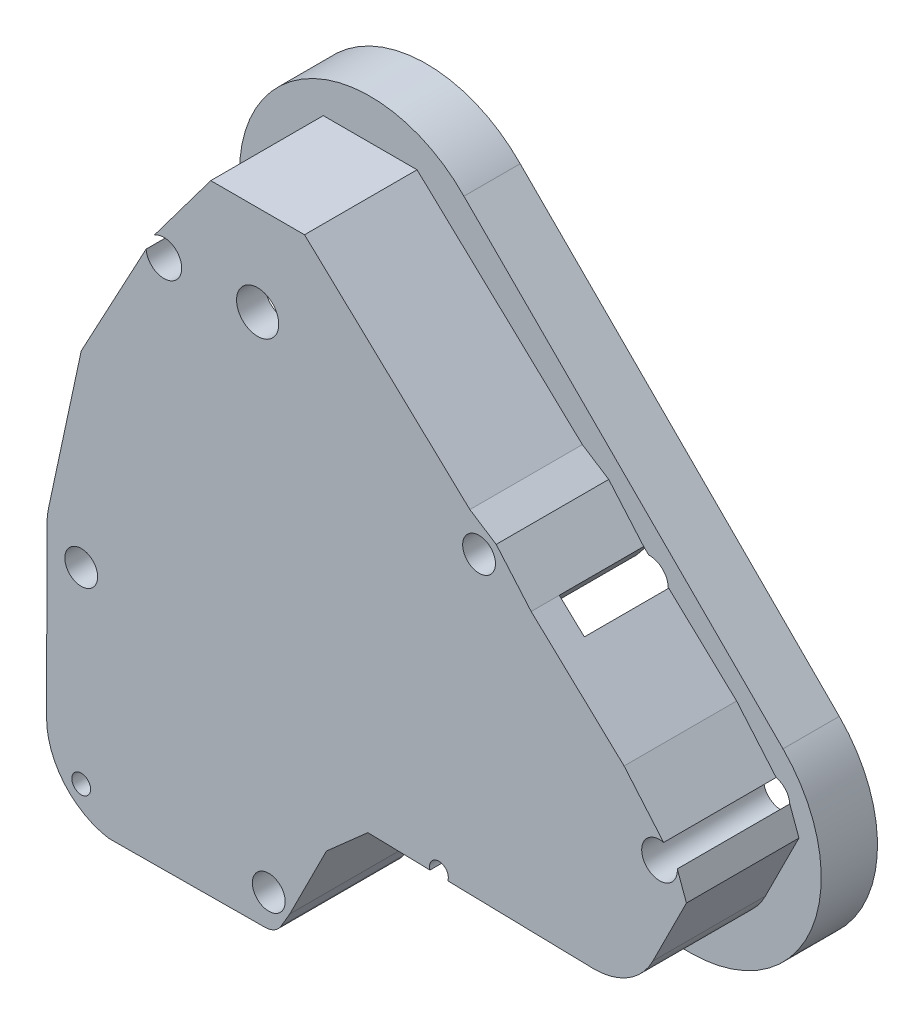
from build123d import *

# Parameters (mm, degrees)
SKETCH1_R                = 4.445
SKETCH1_R_2              = 2.54
BOSS_EXTRUDE1_DEPTH      = 27.94
SKETCH1_4_R              = 4.445
SKETCH1_4_R_2            = 2.667
BOSS_EXTRUDE2_DEPTH      = 5.08
BOSS_EXTRUDE3_DEPTH      = 2.54
BOSS_EXTRUDE4_DEPTH      = 2.54
BOSS_EXTRUDE4_DEPTH_BACK = 12.7
BOSS_EXTRUDE5_DEPTH      = 2.54
CUT_EXTRUDE2_DEPTH       = 28.94
BOSS_EXTRUDE7_DEPTH      = 2.54
SKETCH1_7_R              = 5.715
CUT_EXTRUDE1_DEPTH       = 28.94
BOSS_EXTRUDE6_DEPTH      = 2.54
SKETCH4_R                = 2.54
SKETCH4_R_2              = 4.445
SKETCH4_R_3              = 5.715
BOSS_EXTRUDE8_DEPTH      = 5.08
BOSS_EXTRUDE9_DEPTH      = 5.08


with BuildPart() as part:
    # Sketch1 → Boss-Extrude1 (new body)
    with BuildSketch(Plane.XY):
        with BuildLine():
            Line((6.529742955, -53.858421196), (8.86743597, -49.87006403))
            Line((8.86743597, -49.87006403), (18.794900521, -30.155662993))
            Line((18.794900521, -30.155662993), (30.015464801, -20.224261861))
            Line((30.015464801, -20.224261861), (90.906521033, -21.585518505))
            ThreePointArc((90.906521033, -21.585518505), (100.475537269, -19.041819588), (107.200283399, -11.7744772))
            Line((107.200283399, -11.7744772), (116.311189347, 6.409978492))
            Line((116.311189347, 6.409978492), (113.829291982, 13.184806868))
            ThreePointArc((113.829291982, 13.184806868), (105.340047507, 9.70868308), (110.132255745, 17.530795873))
            Line((110.132255745, 17.530795873), (99.420817942, 30.122447115))
            Line((99.420817942, 30.122447115), (81.037096807, 47.39593724))
            Line((81.037096807, 47.39593724), (81.2028603, 42.898970903))
            Line((81.2028603, 42.898970903), (102.978646989, 17.30080971))
            Line((102.978646989, 17.30080971), (101.915981854, 11.639329767))
            Line((101.915981854, 11.639329767), (108.017908886, 5.157985196))
            Line((108.017908886, 5.157985196), (96.90201237, -15.075571619))
            Line((96.90201237, -15.075571619), (69.399721914, -14.460741167))
            ThreePointArc((69.399721914, -14.460741167), (64.864546386, -17.364816007), (60.463681575, -14.260970544))
            Line((60.463681575, -14.260970544), (49.393136216, -14.01348176))
            Line((49.393136216, -14.01348176), (25.4, -16.5608))
            Line((25.4, -16.5608), (16.5608, -25.4))
            Line((16.5608, -25.4), (3.175, -41.558795918))
            Line((3.175, -41.558795918), (-23.8101989, -24.409795746))
            Line((-23.8101989, -24.409795746), (-41.068354942, 3.175))
            Line((-41.068354942, 3.175), (-41.068354942, 55.377447672))
            Line((-41.068354942, 55.377447672), (-31.251976081, 73.622391025))
            Line((-31.251976081, 73.622391025), (-15.891878201, 82.061036959))
            Line((-15.891878201, 82.061036959), (-10.836023731, 105.600550299))
            Line((-10.836023731, 105.600550299), (2.486172742, 105.600550299))
            Line((2.486172742, 105.600550299), (20.916306787, 88.283450236))
            ThreePointArc((20.916306787, 88.283450236), (28.864622049, 90.486498065), (27.160323343, 82.416522777))
            Line((27.160323343, 82.416522777), (61.243243186, 50.391941083))
            Line((61.243243186, 50.391941083), (64.972407605, 52.198379473))
            Line((64.972407605, 52.198379473), (69.788594683, 48.28291809))
            Line((69.788594683, 48.28291809), (74.25115565, 53.77206135))
            Line((74.25115565, 53.77206135), (64.777919112, 64.777919112))
            Line((64.777919112, 64.777919112), (57.647971379, 69.372544921))
            Line((57.647971379, 69.372544921), (12.859978492, 111.455698118))
            Line((12.859978492, 111.455698118), (-12.540021508, 111.455698118))
            Line((-12.540021508, 111.455698118), (-27.811486315, 91.053304566))
            ThreePointArc((-27.811486315, 91.053304566), (-20.936169847, 84.786075459), (-30.05423809, 86.632414738))
            Line((-30.05423809, 86.632414738), (-47.625, 53.975))
            Line((-47.625, 53.975), (-56.507300171, 12.537235488))
            ThreePointArc((-56.507300171, 12.537235488), (-56.803208534, 10.684397755), (-56.902212174, 8.810693482))
            Line((-56.902212174, 8.810693482), (-56.902212174, -38.910026796))
            ThreePointArc((-56.902212174, -38.910026796), (-51.522576099, -50.610202451), (-40.158446167, -56.667524098))
            Line((-40.158446167, -56.667524098), (2.147088913, -56.369619228))
            ThreePointArc((2.147088913, -56.369619228), (4.672646871, -55.697334849), (6.529742955, -53.858421196))
        make_face()
        with Locations((-47.625, 3.175)):
            Circle(SKETCH1_R, mode=Mode.SUBTRACT)
        with Locations((60.138073453, 60.138073453)):
            Circle(SKETCH1_R, mode=Mode.SUBTRACT)
        with Locations((3.175, -47.625)):
            Circle(SKETCH1_R, mode=Mode.SUBTRACT)
        with Locations((-47.625, -47.625)):
            Circle(SKETCH1_R_2, mode=Mode.SUBTRACT)
    extrude(amount=BOSS_EXTRUDE1_DEPTH)

    # Sketch1_4 → Boss-Extrude2 (add)
    with BuildSketch(Plane.XY):
        with Locations((-47.625, 3.175)):
            Circle(SKETCH1_4_R)
        with Locations((-47.625, 3.175)):
            Circle(SKETCH1_4_R_2, mode=Mode.SUBTRACT)
        with Locations((3.175, -47.625)):
            Circle(SKETCH1_4_R)
        with Locations((3.175, -47.625)):
            Circle(SKETCH1_4_R_2, mode=Mode.SUBTRACT)
        with Locations((60.138073453, 60.138073453)):
            Circle(SKETCH1_4_R)
        with Locations((60.138073453, 60.138073453)):
            Circle(SKETCH1_4_R_2, mode=Mode.SUBTRACT)
    extrude(amount=BOSS_EXTRUDE2_DEPTH)

    # Sketch1_5 → Boss-Extrude3 (add)
    with BuildSketch(Plane.XY):
        with BuildLine():
            ThreePointArc((21.234247588, 108.745854575), (-11.894017134, 114.773008011), (-30.140021508, 86.472975741))
            Line((-30.140021508, 86.472975741), (-30.05423809, 86.632414738))
            ThreePointArc((-30.05423809, 86.632414738), (-29.543873169, 89.152830265), (-27.811486315, 91.053304566))
            Line((-27.811486315, 91.053304566), (-12.540021508, 111.455698118))
            Line((-12.540021508, 111.455698118), (12.859978492, 111.455698118))
            Line((12.859978492, 111.455698118), (57.647971379, 69.372544921))
            Line((57.647971379, 69.372544921), (64.777919112, 64.777919112))
            Line((64.777919112, 64.777919112), (74.25115565, 53.77206135))
            Line((74.25115565, 53.77206135), (75.634193234, 52.472548271))
            ThreePointArc((75.634193234, 52.472548271), (76.84224881, 52.371963391), (77.992077705, 51.988024458))
            Line((77.992077705, 51.988024458), (59.152987425, 70.827114739))
            Line((59.152987425, 70.827114739), (21.936380205, 108.043721958))
            Line((21.936380205, 108.043721958), (21.234247588, 108.745854575))
        make_face()
    extrude(amount=BOSS_EXTRUDE3_DEPTH)

    # Sketch1_6 → Boss-Extrude4 (add, two sides)
    with BuildSketch(Plane.XY) as boss_extrude4_sk:
        with BuildLine():
            Line((86.969452862, -30.140021416), (57.15, -30.140021416))
            Line((57.15, -30.140021416), (57.15, -35.220021416))
            Line((57.15, -35.220021416), (86.969452862, -35.220021416))
            ThreePointArc((86.969452862, -35.220021416), (119.656310637, -13.37936131), (111.986890715, 25.177416345))
            Line((111.986890715, 25.177416345), (62.745089873, 74.419217187))
            Line((62.745089873, 74.419217187), (25.556770339, 111.607536721))
            ThreePointArc((25.556770339, 111.607536721), (-13.380914996, 119.660069496), (-35.220021508, 86.432971366))
            Line((-35.220021508, 86.432971366), (-35.220021508, 77.031173063))
            Line((-35.220021508, 77.031173063), (-30.140021508, 86.472975741))
            ThreePointArc((-30.140021508, 86.472975741), (-11.894017134, 114.773008011), (21.234247588, 108.745854575))
            ThreePointArc((21.234247588, 108.745854575), (21.588189914, 108.397664284), (21.936380205, 108.043721958))
            Line((21.936380205, 108.043721958), (59.152987425, 70.827114739))
            Line((59.152987425, 70.827114739), (77.992077705, 51.988024458))
            ThreePointArc((77.992077705, 51.988024458), (79.411823143, 50.988039688), (80.411807913, 49.56829425))
            Line((80.411807913, 49.56829425), (108.394788266, 21.585313897))
            ThreePointArc((108.394788266, 21.585313897), (114.963002612, -11.435329473), (86.969452862, -30.140021416))
        make_face()
    extrude(amount=BOSS_EXTRUDE4_DEPTH)
    extrude(boss_extrude4_sk.sketch, amount=-BOSS_EXTRUDE4_DEPTH_BACK)

    # Sketch1_10 → Cut-Extrude2 (cut, through all)
    with BuildSketch(Plane.XY):
        with BuildLine():
            ThreePointArc((49.319303811, -17.316116234), (47.237072506, -18.322803482), (46.834178588, -20.60025445))
            Line((46.834178588, -20.60025445), (51.655181806, -20.708030913))
            ThreePointArc((51.655181806, -20.708030913), (51.354467139, -18.414850346), (49.319303811, -17.316116234))
        make_face()
    extrude(amount=CUT_EXTRUDE2_DEPTH, mode=Mode.SUBTRACT)

    # Sketch1_11 → Boss-Extrude7 (add)
    with BuildSketch(Plane.XY):
        with BuildLine():
            Line((90.906521033, -21.585518505), (57.15, -20.83087092))
            Line((57.15, -20.83087092), (57.15, -30.140021416))
            Line((57.15, -30.140021416), (86.969452862, -30.140021416))
            ThreePointArc((86.969452862, -30.140021416), (114.963002612, -11.435329473), (108.394788266, 21.585313897))
            Line((108.394788266, 21.585313897), (80.411807913, 49.56829425))
            ThreePointArc((80.411807913, 49.56829425), (80.761514312, 48.572829693), (80.89804013, 47.526595995))
            Line((80.89804013, 47.526595995), (81.037096807, 47.39593724))
            Line((81.037096807, 47.39593724), (99.420817942, 30.122447115))
            Line((99.420817942, 30.122447115), (110.132255745, 17.530795873))
            ThreePointArc((110.132255745, 17.530795873), (112.691826368, 15.96267793), (113.829291982, 13.184806868))
            Line((113.829291982, 13.184806868), (116.311189347, 6.409978492))
            Line((116.311189347, 6.409978492), (107.200283399, -11.7744772))
            ThreePointArc((107.200283399, -11.7744772), (100.475537269, -19.041819588), (90.906521033, -21.585518505))
        make_face()
    extrude(amount=BOSS_EXTRUDE7_DEPTH)

    # Sketch1_9 → Boss-Extrude6 (add)
    with BuildSketch(Plane.XY):
        with BuildLine():
            Line((90.906521033, -21.585518505), (57.15, -20.83087092))
            Line((57.15, -20.83087092), (57.15, -30.140021416))
            Line((57.15, -30.140021416), (86.969452862, -30.140021416))
            ThreePointArc((86.969452862, -30.140021416), (114.963002612, -11.435329473), (108.394788266, 21.585313897))
            Line((108.394788266, 21.585313897), (80.411807913, 49.56829425))
            ThreePointArc((80.411807913, 49.56829425), (80.761514312, 48.572829693), (80.89804013, 47.526595995))
            Line((80.89804013, 47.526595995), (81.037096807, 47.39593724))
            Line((81.037096807, 47.39593724), (99.420817942, 30.122447115))
            Line((99.420817942, 30.122447115), (110.132255745, 17.530795873))
            ThreePointArc((110.132255745, 17.530795873), (112.691826368, 15.96267793), (113.829291982, 13.184806868))
            Line((113.829291982, 13.184806868), (116.311189347, 6.409978492))
            Line((116.311189347, 6.409978492), (107.200283399, -11.7744772))
            ThreePointArc((107.200283399, -11.7744772), (100.475537269, -19.041819588), (90.906521033, -21.585518505))
        make_face()
    extrude(amount=BOSS_EXTRUDE6_DEPTH)



with BuildPart() as body_2:
    # Sketch2 → Boss-Extrude5 (new body)
    with BuildSketch(Plane.XY.offset(27.94)):
        with BuildLine():
            Line((-10.836023731, 105.600550299), (-15.891878201, 82.061036959))
            Line((-15.891878201, 82.061036959), (-31.251976081, 73.622391025))
            Line((-31.251976081, 73.622391025), (-41.068354942, 55.377447672))
            Line((-41.068354942, 55.377447672), (-41.068354942, 3.175))
            Line((-41.068354942, 3.175), (-23.8101989, -24.409795746))
            Line((-23.8101989, -24.409795746), (3.175, -41.558795918))
            Line((3.175, -41.558795918), (16.5608, -25.4))
            Line((16.5608, -25.4), (25.4, -16.5608))
            Line((25.4, -16.5608), (49.393136216, -14.01348176))
            Line((49.393136216, -14.01348176), (60.463681575, -14.260970544))
            ThreePointArc((60.463681575, -14.260970544), (64.864546386, -17.364816007), (69.399721914, -14.460741167))
            Line((69.399721914, -14.460741167), (96.90201237, -15.075571619))
            Line((96.90201237, -15.075571619), (108.017908886, 5.157985196))
            Line((108.017908886, 5.157985196), (101.915981854, 11.639329767))
            Line((101.915981854, 11.639329767), (102.978646989, 17.30080971))
            Line((102.978646989, 17.30080971), (81.2028603, 42.898970903))
            Line((81.2028603, 42.898970903), (81.037096807, 47.39593724))
            Line((81.037096807, 47.39593724), (74.25115565, 53.77206135))
            Line((74.25115565, 53.77206135), (69.788594683, 48.28291809))
            Line((69.788594683, 48.28291809), (64.972407605, 52.198379473))
            Line((64.972407605, 52.198379473), (61.243243186, 50.391941083))
            Line((61.243243186, 50.391941083), (27.160323343, 82.416522777))
            ThreePointArc((27.160323343, 82.416522777), (28.864622049, 90.486498065), (20.916306787, 88.283450236))
            Line((20.916306787, 88.283450236), (2.486172742, 105.600550299))
            Line((2.486172742, 105.600550299), (-10.836023731, 105.600550299))
        make_face()
    extrude(amount=-BOSS_EXTRUDE5_DEPTH)

    # Sketch1_7 → Cut-Extrude1 (cut, through all)
    with BuildSketch(Plane.XY):
        with Locations((0.159978492, 86.969452862)):
            Circle(SKETCH1_7_R)
        with Locations((86.969452862, 0.159978492)):
            Circle(SKETCH1_7_R)
    extrude(amount=CUT_EXTRUDE1_DEPTH, mode=Mode.SUBTRACT)


with BuildPart() as part_1:
    add(part.part)

    add(body_2.part)  # Boss-Extrude8 merges body 2
    # Sketch4 → Boss-Extrude8 (add)
    with BuildSketch(Plane.XY.offset(27.94)):
        with BuildLine():
            ThreePointArc((-57.015177886, -36.778748499), (-52.234105183, -49.814399605), (-40.158446167, -56.667524098))
            Line((-40.158446167, -56.667524098), (2.147088913, -56.369619228))
            ThreePointArc((2.147088913, -56.369619228), (4.672646871, -55.697334849), (6.529742955, -53.858421196))
            Line((6.529742955, -53.858421196), (8.86743597, -49.87006403))
            Line((8.86743597, -49.87006403), (18.794900521, -30.155662993))
            Line((18.794900521, -30.155662993), (30.015464801, -20.224261861))
            Line((30.015464801, -20.224261861), (46.834178588, -20.60025445))
            ThreePointArc((46.834178588, -20.60025445), (49.319303811, -17.316116234), (51.655181806, -20.708030913))
            Line((51.655181806, -20.708030913), (91.303904472, -21.589959824))
            ThreePointArc((91.303904472, -21.589959824), (100.64519135, -18.938368844), (107.200283399, -11.7744772))
            Line((107.200283399, -11.7744772), (116.311189347, 6.409978492))
            Line((116.311189347, 6.409978492), (113.829291982, 13.184806868))
            ThreePointArc((113.829291982, 13.184806868), (105.340047507, 9.70868308), (110.132255745, 17.530795873))
            Line((110.132255745, 17.530795873), (99.420817942, 30.122447115))
            Line((99.420817942, 30.122447115), (74.25115565, 53.77206135))
            Line((74.25115565, 53.77206135), (64.777919112, 64.777919112))
            Line((64.777919112, 64.777919112), (57.647971379, 69.372544921))
            Line((57.647971379, 69.372544921), (12.859978492, 111.455698118))
            Line((12.859978492, 111.455698118), (-12.540021508, 111.455698118))
            Line((-12.540021508, 111.455698118), (-27.811486315, 91.053304566))
            ThreePointArc((-27.811486315, 91.053304566), (-20.936169847, 84.786075459), (-30.05423809, 86.632414738))
            Line((-30.05423809, 86.632414738), (-47.625, 53.975))
            Line((-47.625, 53.975), (-56.507300171, 12.537235488))
            Line((-56.507300171, 12.537235488), (-56.902212174, 8.810693482))
            Line((-56.902212174, 8.810693482), (-57.015177886, -36.778748499))
        make_face()
        with Locations((-47.625, -47.625)):
            Circle(SKETCH4_R, mode=Mode.SUBTRACT)
        with Locations((3.175, -47.625)):
            Circle(SKETCH4_R_2, mode=Mode.SUBTRACT)
        with Locations((-47.625, 3.175)):
            Circle(SKETCH4_R_2, mode=Mode.SUBTRACT)
        with Locations((0.159978492, 86.969452862)):
            Circle(SKETCH4_R_3, mode=Mode.SUBTRACT)
        with Locations((60.138073453, 60.138073453)):
            Circle(SKETCH4_R_2, mode=Mode.SUBTRACT)
    extrude(amount=BOSS_EXTRUDE8_DEPTH)

    # Sketch5 → Boss-Extrude9 (add)
    with BuildSketch(Plane.XY.offset(27.94)):
        Polygon((-56.902212174, 8.810693482), (-56.507300171, 12.537235488), (-56.803208534, 10.684397755), align=None)
    extrude(amount=BOSS_EXTRUDE9_DEPTH)


solid = part_1.part
